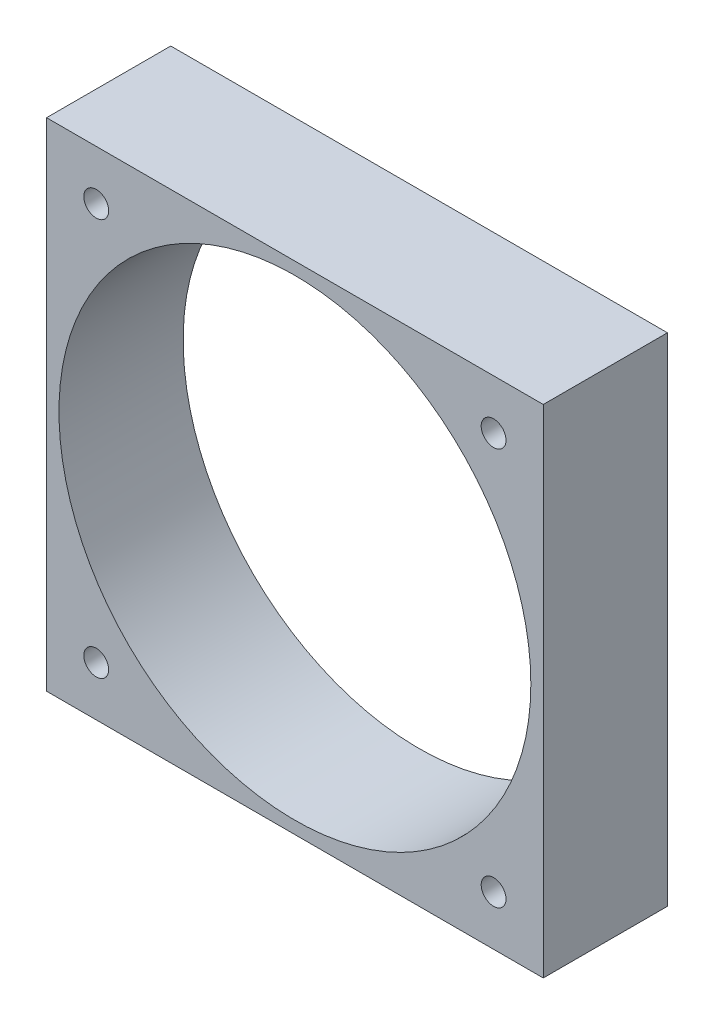
from build123d import *

# Parameters (mm, degrees)
SKETCH1_W           = 40
SKETCH1_H           = 40
BOSS_EXTRUDE1_DEPTH = 10
SKETCH2_R           = 1
CUT_EXTRUDE1_DEPTH  = 11
SKETCH3_R           = 19
CUT_EXTRUDE2_DEPTH  = 11


with BuildPart() as part:
    # Sketch1 → Boss-Extrude1 (new body)
    with BuildSketch(Plane.XY):
        with Locations((20, 20)):
            Rectangle(SKETCH1_W, SKETCH1_H)
    extrude(amount=BOSS_EXTRUDE1_DEPTH)

    # Sketch2 → Cut-Extrude1 (cut, through all)
    with BuildSketch(Plane.XY.offset(10)):
        with Locations((36, 36)):
            Circle(SKETCH2_R)
        with Locations((4, 36)):
            Circle(SKETCH2_R)
        with Locations((4, 4)):
            Circle(SKETCH2_R)
        with Locations((36, 4)):
            Circle(SKETCH2_R)
    extrude(amount=-CUT_EXTRUDE1_DEPTH, mode=Mode.SUBTRACT)

    # Sketch3 → Cut-Extrude2 (cut, through all)
    with BuildSketch(Plane.XY.offset(10)):
        with Locations((20, 20)):
            Circle(SKETCH3_R)
    extrude(amount=-CUT_EXTRUDE2_DEPTH, mode=Mode.SUBTRACT)


solid = part.part
